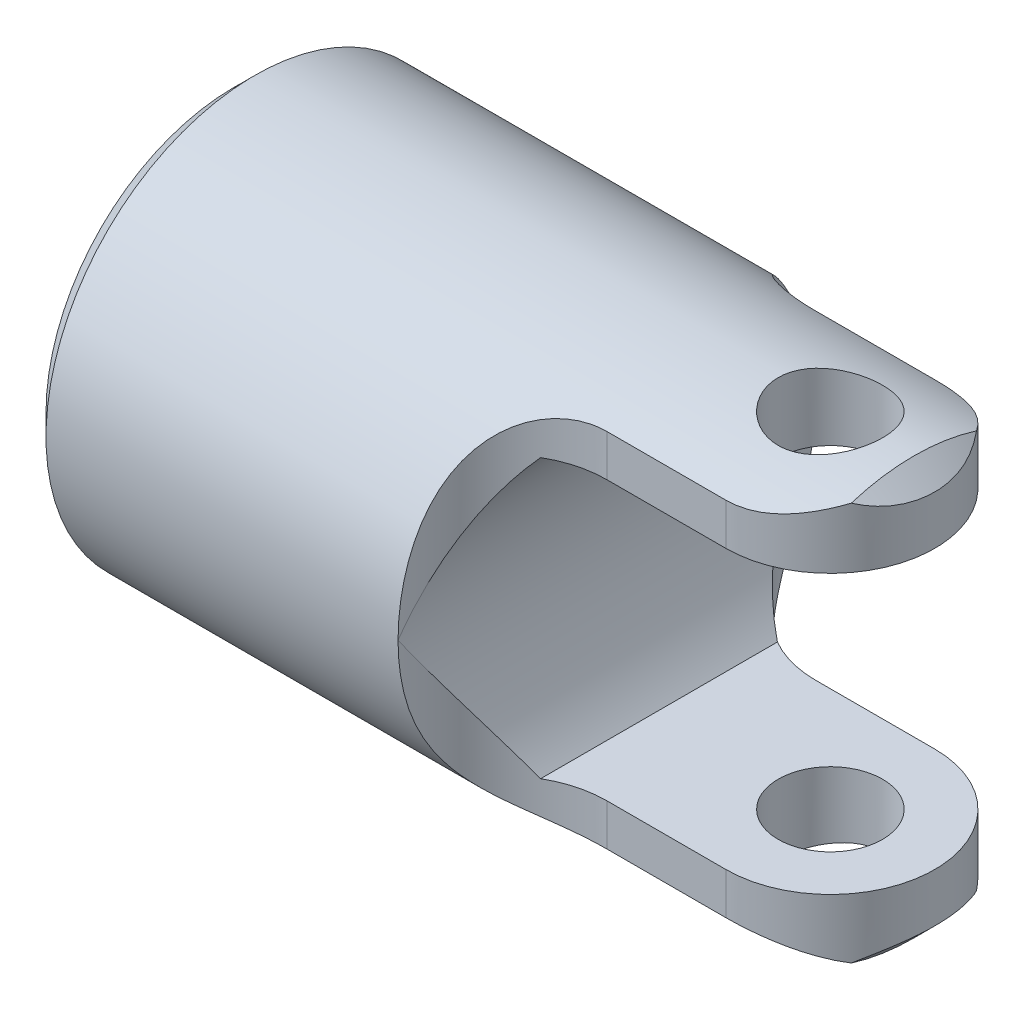
from build123d import *

# Parameters (mm, degrees)
CHAMFER1_SIZE       = 2.2225
EXTRUDE1_DEPTH      = 71.853025694
EXTRUDE1_DEPTH_BACK = 71.853025694
EXTRUDE3_DEPTH      = 71.853025757
EXTRUDE3_DEPTH_BACK = 71.853025757
SKETCH4_R           = 3.175
EXTRUDE4_DEPTH      = 6.35
EXTRUDE6_DEPTH      = 71.853025757
EXTRUDE6_DEPTH_BACK = 71.853025757
SKETCH6_R           = 5.55625


with BuildPart() as part:
    # Sketch1 → Revolve1 (revolve)
    with BuildSketch(Plane(origin=(0, 0, 0), x_dir=(1, 0, 0), z_dir=(0, 1, 0)), mode=Mode.PRIVATE) as revolve1_sk:
        Polygon((-63.5, 22.225), (-23.01875, 22.225), (11.1125, 22.225), (11.1125, 0), (-63.5, 0), align=None)
    revolve(revolve1_sk.sketch.rotate(Axis((-63.5, 0, 0), (1, 0, 0)), 180), axis=Axis((-63.5, 0, 0), (1, 0, 0)))

    # Chamfer1
    chamfer1_edges = [part.edges().sort_by_distance(p)[0] for p in [
        (11.1125, 0, -22.225),
        (-63.5, 0, -22.225),
    ]]
    chamfer(chamfer1_edges, length=CHAMFER1_SIZE)

    # Sketch2 → Extrude1 (cut, two sides: drawn at the far end of the back side and taken through both)
    with BuildSketch(Plane(origin=(0, 0, 0), x_dir=(1, 0, 0), z_dir=(0, 1, 0)).offset(-EXTRUDE1_DEPTH_BACK)):
        with BuildLine():
            Line((-23.7998, 22.225), (22.225, 22.225))
            Line((22.225, 22.225), (22.225, -22.225))
            Line((22.225, -22.225), (-23.7998, -22.225))
            ThreePointArc((-23.7998, -22.225), (-20.545024106, -14.367275894), (-12.6873, -11.1125))
            Line((-12.6873, -11.1125), (0, -11.1125))
            ThreePointArc((0, -11.1125), (11.1125, 0), (0, 11.1125))
            Line((0, 11.1125), (-12.6873, 11.1125))
            ThreePointArc((-12.6873, 11.1125), (-20.545024106, 14.367275894), (-23.7998, 22.225))
        make_face()
    extrude(amount=EXTRUDE1_DEPTH + EXTRUDE1_DEPTH_BACK, mode=Mode.SUBTRACT)

    # Sketch3 → Extrude3 (cut, two sides: drawn at the far end of the back side and taken through both)
    with BuildSketch(Plane.XY.offset(-EXTRUDE3_DEPTH_BACK)):
        with BuildLine():
            Line((-18.24355, 14.80185), (22.225, 14.80185))
            Line((22.225, 14.80185), (22.225, -14.80185))
            Line((22.225, -14.80185), (-18.24355, -14.80185))
            ThreePointArc((-18.24355, -14.80185), (-23.7998, 0), (-18.24355, 14.80185))
        make_face()
    extrude(amount=EXTRUDE3_DEPTH + EXTRUDE3_DEPTH_BACK, mode=Mode.SUBTRACT)

    # Sketch4 → Extrude4 (cut)
    with BuildSketch(Plane.ZY.offset(63.5)):
        Circle(SKETCH4_R)
    extrude(amount=-EXTRUDE4_DEPTH, mode=Mode.SUBTRACT)

    # Extrude5 cone 1 section (through the dimple's axis) → Extrude5 (revolve, cut)
    with BuildSketch(Plane(origin=(-57.15, 0, 0), x_dir=(0, 0, 1), z_dir=(0, 1, 0))):
        Polygon((0, 0), (3.175, 0), (0, 3.175), align=None)
    revolve(axis=Axis((-57.15, 0, 0), (1, 0, 0)), mode=Mode.SUBTRACT)

    # Sketch6 → Extrude6 (cut, two sides: drawn at the far end of the back side and taken through both)
    with BuildSketch(Plane(origin=(0, 0, 0), x_dir=(1, 0, 0), z_dir=(0, 1, 0)).offset(-EXTRUDE6_DEPTH_BACK)):
        with Locations(Location((0, 0, 0), (0, 0, 270))):
            Circle(SKETCH6_R)
    extrude(amount=EXTRUDE6_DEPTH + EXTRUDE6_DEPTH_BACK, mode=Mode.SUBTRACT)


solid = part.part
